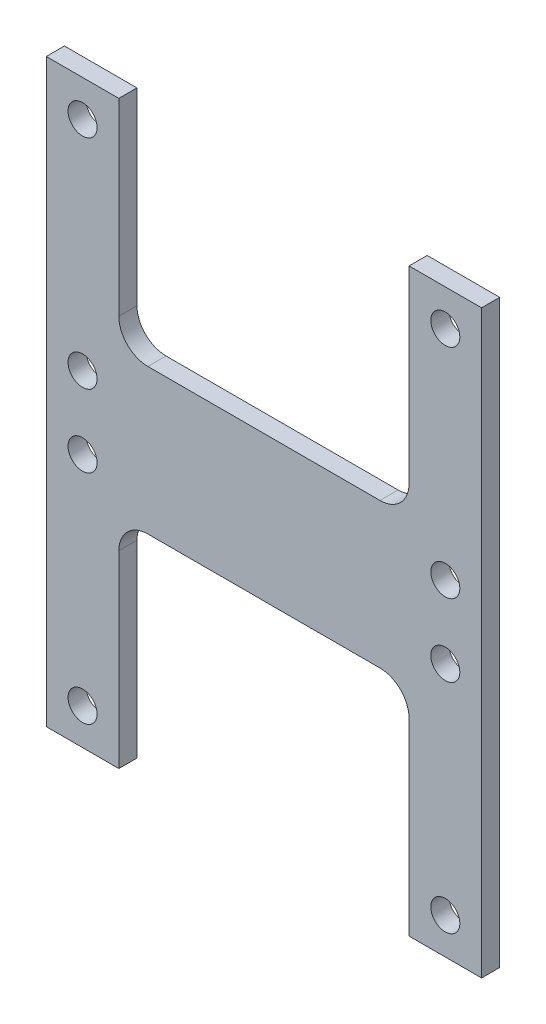
from build123d import *

# Parameters (mm, degrees)
BOSS_EXTRUDE1_DEPTH = 3.175
SKETCH4_R           = 2.54
CUT_EXTRUDE3_DEPTH  = 4.175
FILLET1_R           = 5.08


with BuildPart() as part:
    # Sketch1 → Boss-Extrude1 (new body)
    with BuildSketch(Plane.XY):
        Polygon((-38.1, 50.8), (-25.4, 50.8), (-25.4, 12.7), (25.4, 12.7), (25.4, 50.8), (38.1, 50.8), (38.1, -50.8), (25.4, -50.8), (25.4, -12.7), (-25.4, -12.7), (-25.4, -50.8), (-38.1, -50.8), align=None)
    extrude(amount=BOSS_EXTRUDE1_DEPTH)

    # Sketch4 → Cut-Extrude3 (cut, through all)
    with BuildSketch(Plane.XY.offset(3.175)):
        with Locations((-31.75, 44.45)):
            Circle(SKETCH4_R)
        with Locations((-31.75, 6.35)):
            Circle(SKETCH4_R)
        with Locations((31.75, 6.35)):
            Circle(SKETCH4_R)
        with Locations((31.75, 44.45)):
            Circle(SKETCH4_R)
        with Locations((-31.75, -6.35)):
            Circle(SKETCH4_R)
        with Locations((31.75, -6.35)):
            Circle(SKETCH4_R)
        with Locations((31.75, -44.45)):
            Circle(SKETCH4_R)
        with Locations((-31.75, -44.45)):
            Circle(SKETCH4_R)
    extrude(amount=-CUT_EXTRUDE3_DEPTH, mode=Mode.SUBTRACT)

    # Fillet1
    fillet1_edges = [part.edges().sort_by_distance(p)[0] for p in [
        (25.4, -12.7, 1.5875),
        (-25.4, -12.7, 1.5875),
        (-25.4, 12.7, 1.5875),
        (25.4, 12.7, 1.5875),
    ]]
    fillet(fillet1_edges, radius=FILLET1_R)


solid = part.part
